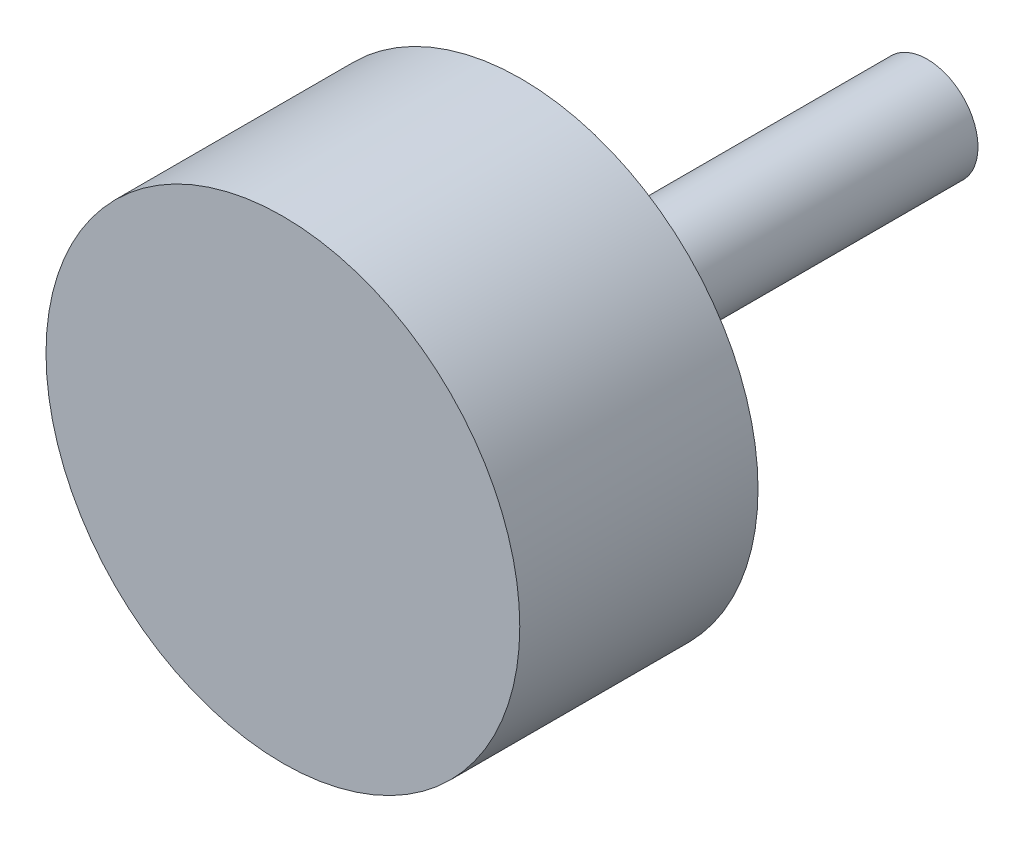
from build123d import *

# Parameters (mm, degrees)
SKETCH1_R           = 22.225
BOSS_EXTRUDE1_DEPTH = 22.352
SKETCH2_R           = 4.7625
BOSS_EXTRUDE2_DEPTH = 38.1


with BuildPart() as part:
    # Sketch1 → Boss-Extrude1 (new body)
    with BuildSketch(Plane.XY):
        Circle(SKETCH1_R)
    extrude(amount=BOSS_EXTRUDE1_DEPTH)

    # Sketch2 → Boss-Extrude2 (add)
    with BuildSketch(Plane.XY):
        Circle(SKETCH2_R)
    extrude(amount=-BOSS_EXTRUDE2_DEPTH)


solid = part.part
